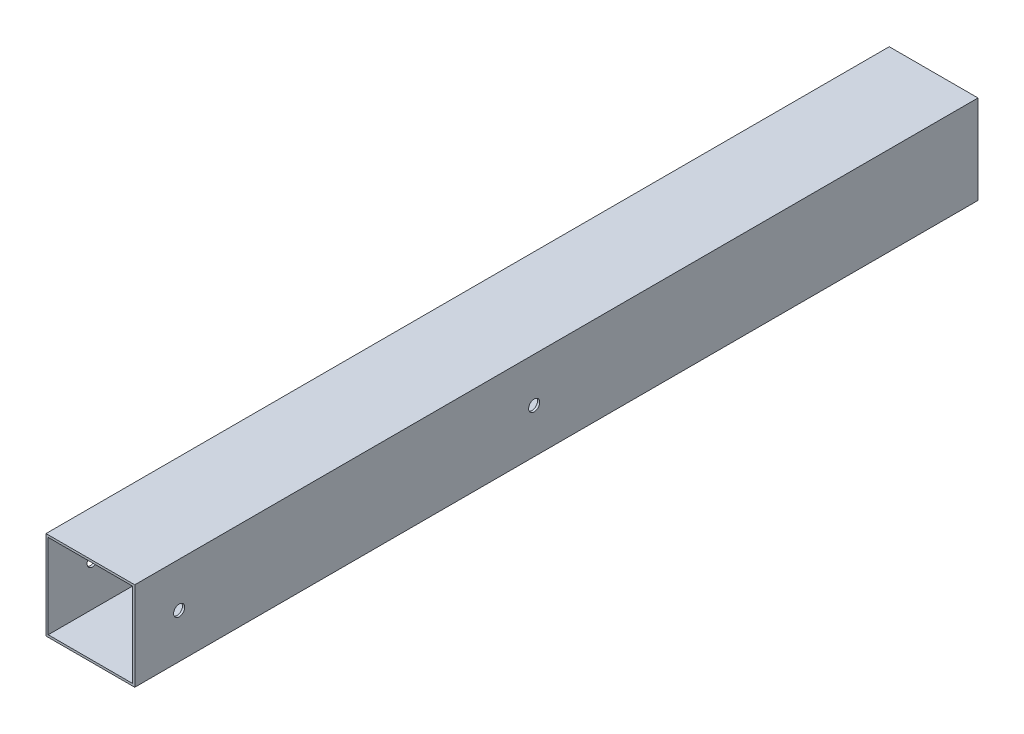
from build123d import *

# Parameters (mm, degrees)
SCHIZZO1_W                   = 40
SCHIZZO1_H                   = 40
SCHIZZO1_W_2                 = 38
SCHIZZO1_H_2                 = 38
ESTRUSIONE_ESTRUSIONE2_DEPTH = 380
SCHIZZO2_R                   = 2.5
TAGLIO_ESTRUSIONE1_DEPTH     = 41


with BuildPart() as part:
    # Schizzo1 → Estrusione-Estrusione2 (new body)
    with BuildSketch(Plane.XY):
        Rectangle(SCHIZZO1_W, SCHIZZO1_H)
        Rectangle(SCHIZZO1_W_2, SCHIZZO1_H_2, mode=Mode.SUBTRACT)
    extrude(amount=ESTRUSIONE_ESTRUSIONE2_DEPTH)

    # Schizzo2 → Taglio-Estrusione1 (cut, through all)
    with BuildSketch(Plane(origin=(20, 0, 0), x_dir=(0, 0, -1), z_dir=(1, 0, 0))):
        with Locations((-360, 0)):
            Circle(SCHIZZO2_R)
        with Locations((-200, 0)):
            Circle(SCHIZZO2_R)
    extrude(amount=-TAGLIO_ESTRUSIONE1_DEPTH, mode=Mode.SUBTRACT)


solid = part.part
